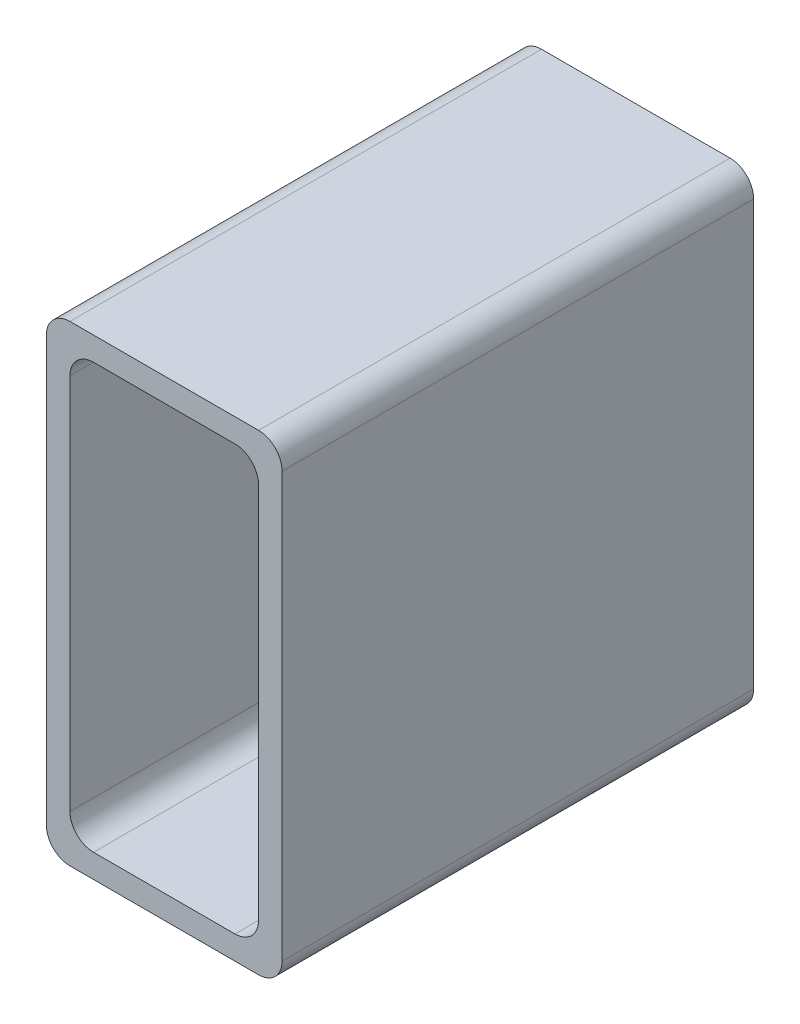
from build123d import *

# Parameters (mm, degrees)
SZKIC1_W                    = 24
SZKIC1_H                    = 54
DODANIE_WYCI_GNI_CIE1_DEPTH = 60
ZAOKR_GLENIE1_R             = 3


with BuildPart() as part:
    # Szkic1 → Dodanie-wyciągnięcie1 (new body)
    with BuildSketch(Plane.XY):
        with BuildLine():
            Line((-12, -30), (12, -30))
            ThreePointArc((12, -30), (14.121320344, -29.121320344), (15, -27))
            Line((15, -27), (15, 27))
            ThreePointArc((15, 27), (14.121320344, 29.121320344), (12, 30))
            Line((12, 30), (-12, 30))
            ThreePointArc((-12, 30), (-14.121320344, 29.121320344), (-15, 27))
            Line((-15, 27), (-15, -27))
            ThreePointArc((-15, -27), (-14.121320344, -29.121320344), (-12, -30))
        make_face()
        Rectangle(SZKIC1_W, SZKIC1_H, mode=Mode.SUBTRACT)
    extrude(amount=DODANIE_WYCI_GNI_CIE1_DEPTH)

    # Zaokrąglenie1
    zaokr_glenie1_edges = [part.edges().sort_by_distance(p)[0] for p in [
        (-12, 27, 30),
        (-12, -27, 30),
        (12, -27, 30),
        (12, 27, 30),
    ]]
    fillet(zaokr_glenie1_edges, radius=ZAOKR_GLENIE1_R)


solid = part.part
